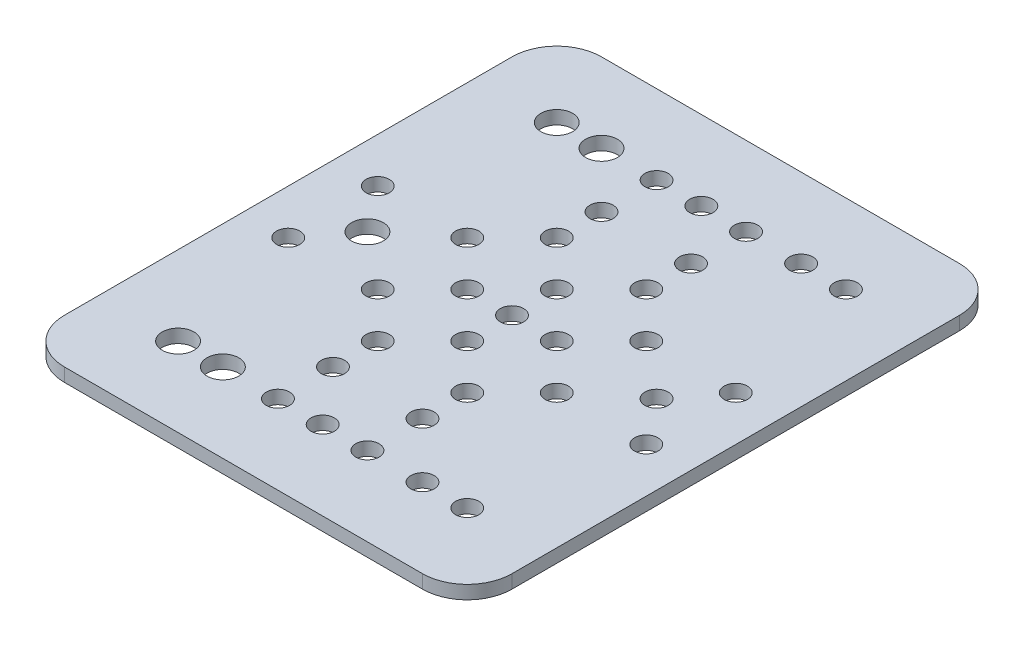
from build123d import *

# Parameters (mm, degrees)
SKETCH1_R           = 3.55
SKETCH1_R_2         = 2.6
BOSS_EXTRUDE1_DEPTH = 3


with BuildPart() as part:
    # Sketch1 → Boss-Extrude1 (new body)
    with BuildSketch(Plane(origin=(0, 0, 0), x_dir=(1, 0, 0), z_dir=(0, 1, 0))):
        with BuildLine():
            Line((40, -60), (-40, -60))
            ThreePointArc((-40, -60), (-47.071067812, -57.071067812), (-50, -50))
            Line((-50, -50), (-50, 50))
            ThreePointArc((-50, 50), (-47.071067812, 57.071067812), (-40, 60))
            Line((-40, 60), (40, 60))
            ThreePointArc((40, 60), (47.071067812, 57.071067812), (50, 50))
            Line((50, 50), (50, -50))
            ThreePointArc((50, -50), (47.071067812, -57.071067812), (40, -60))
        make_face()
        with Locations((-22.3, 42.3)):
            Circle(SKETCH1_R, mode=Mode.SUBTRACT)
        with Locations((0, 10)):
            Circle(SKETCH1_R_2, mode=Mode.SUBTRACT)
        Circle(SKETCH1_R_2, mode=Mode.SUBTRACT)
        with Locations((10, 0)):
            Circle(SKETCH1_R_2, mode=Mode.SUBTRACT)
        with Locations((-10, 0)):
            Circle(SKETCH1_R_2, mode=Mode.SUBTRACT)
        with Locations((-32.3, 42.3)):
            Circle(SKETCH1_R, mode=Mode.SUBTRACT)
        with Locations((-32.3, 0)):
            Circle(SKETCH1_R, mode=Mode.SUBTRACT)
        with Locations((-32.3, -42.3)):
            Circle(SKETCH1_R, mode=Mode.SUBTRACT)
        with Locations((-20, 10)):
            Circle(SKETCH1_R_2, mode=Mode.SUBTRACT)
        with Locations((-40, 10)):
            Circle(SKETCH1_R_2, mode=Mode.SUBTRACT)
        with Locations((-10, 20)):
            Circle(SKETCH1_R_2, mode=Mode.SUBTRACT)
        with Locations((-10, 30)):
            Circle(SKETCH1_R_2, mode=Mode.SUBTRACT)
        with Locations((-10, 42.3)):
            Circle(SKETCH1_R_2, mode=Mode.SUBTRACT)
        with Locations((0, 42.3)):
            Circle(SKETCH1_R_2, mode=Mode.SUBTRACT)
        with Locations((10, 42.3)):
            Circle(SKETCH1_R_2, mode=Mode.SUBTRACT)
        with Locations((10, 30)):
            Circle(SKETCH1_R_2, mode=Mode.SUBTRACT)
        with Locations((10, 20)):
            Circle(SKETCH1_R_2, mode=Mode.SUBTRACT)
        with Locations((20, 10)):
            Circle(SKETCH1_R_2, mode=Mode.SUBTRACT)
        with Locations((40, 10)):
            Circle(SKETCH1_R_2, mode=Mode.SUBTRACT)
        with Locations((22.3, 42.3)):
            Circle(SKETCH1_R_2, mode=Mode.SUBTRACT)
        with Locations((32.3, 42.3)):
            Circle(SKETCH1_R_2, mode=Mode.SUBTRACT)
        with Locations((32.3, 0)):
            Circle(SKETCH1_R_2, mode=Mode.SUBTRACT)
        with Locations((40, -10)):
            Circle(SKETCH1_R_2, mode=Mode.SUBTRACT)
        with Locations((32.3, -42.3)):
            Circle(SKETCH1_R_2, mode=Mode.SUBTRACT)
        with Locations((22.3, -42.3)):
            Circle(SKETCH1_R_2, mode=Mode.SUBTRACT)
        with Locations((20, -10)):
            Circle(SKETCH1_R_2, mode=Mode.SUBTRACT)
        with Locations((0, -10)):
            Circle(SKETCH1_R_2, mode=Mode.SUBTRACT)
        with Locations((10, -20)):
            Circle(SKETCH1_R_2, mode=Mode.SUBTRACT)
        with Locations((10, -30)):
            Circle(SKETCH1_R_2, mode=Mode.SUBTRACT)
        with Locations((10, -42.3)):
            Circle(SKETCH1_R_2, mode=Mode.SUBTRACT)
        with Locations((0, -42.3)):
            Circle(SKETCH1_R_2, mode=Mode.SUBTRACT)
        with Locations((-10, -42.3)):
            Circle(SKETCH1_R_2, mode=Mode.SUBTRACT)
        with Locations((-10, -30)):
            Circle(SKETCH1_R_2, mode=Mode.SUBTRACT)
        with Locations((-10, -20)):
            Circle(SKETCH1_R_2, mode=Mode.SUBTRACT)
        with Locations((-20, -10)):
            Circle(SKETCH1_R_2, mode=Mode.SUBTRACT)
        with Locations((-40, -10)):
            Circle(SKETCH1_R_2, mode=Mode.SUBTRACT)
        with Locations((-22.3, -42.3)):
            Circle(SKETCH1_R, mode=Mode.SUBTRACT)
    extrude(amount=BOSS_EXTRUDE1_DEPTH)


solid = part.part
